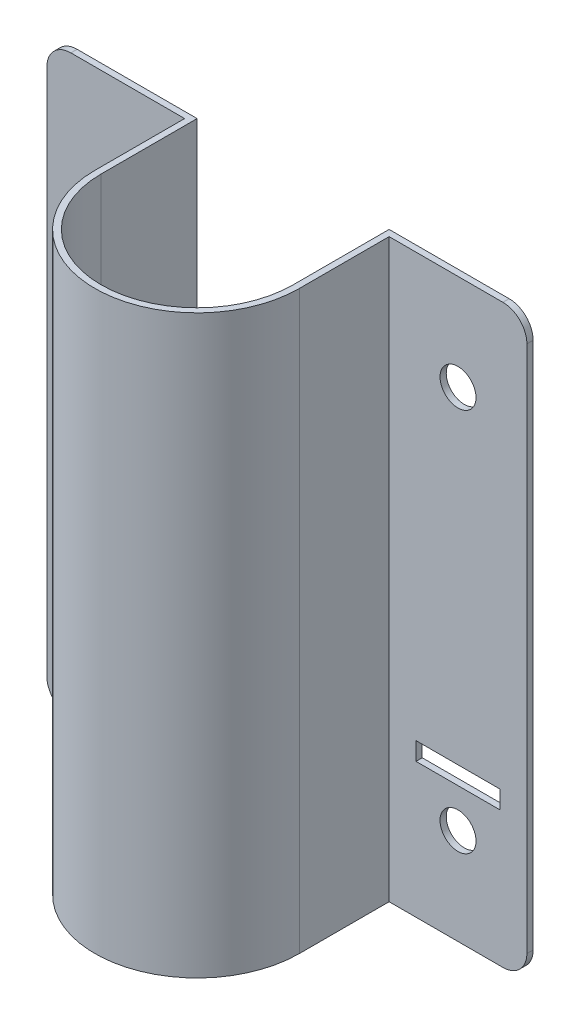
from build123d import *

# Parameters (mm, degrees)
BOSS_EXTRUDE1_DEPTH = 152.4
SKETCH2_R           = 4.7625
CUT_EXTRUDE1_DEPTH  = 50.8
FILLET1_R           = 6.35
SKETCH3_W           = 22.225
SKETCH3_H           = 4.7625
CUT_EXTRUDE3_DEPTH  = 2.651


with BuildPart() as part:
    # Sketch1 → Boss-Extrude1 (new body)
    with BuildSketch(Plane(origin=(0, 0, 0), x_dir=(1, 0, 0), z_dir=(0, 1, 0))):
        with BuildLine():
            Line((-27.051, 0), (-27.051, 23.749))
            Line((-27.051, 23.749), (-63.5, 23.749))
            Line((-63.5, 23.749), (-63.5, 25.4))
            Line((-63.5, 25.4), (-25.4, 25.4))
            Line((-25.4, 25.4), (-25.4, 0))
            ThreePointArc((-25.4, 0), (0, -25.4), (25.4, 0))
            Line((25.4, 0), (25.4, 25.4))
            Line((25.4, 25.4), (63.5, 25.4))
            Line((63.5, 25.4), (63.5, 23.749))
            Line((63.5, 23.749), (27.051, 23.749))
            Line((27.051, 23.749), (27.051, 0))
            ThreePointArc((27.051, 0), (0, -27.051), (-27.051, 0))
        make_face()
    extrude(amount=-BOSS_EXTRUDE1_DEPTH)

    # Sketch2 → Cut-Extrude1 (cut)
    with BuildSketch(Plane.XY.offset(-23.749)):
        with Locations((-45.2755, -25.4)):
            Circle(SKETCH2_R)
        with Locations((45.2755, -25.4)):
            Circle(SKETCH2_R)
        with Locations((-45.2755, -127)):
            Circle(SKETCH2_R)
        with Locations((45.2755, -127)):
            Circle(SKETCH2_R)
    extrude(amount=-CUT_EXTRUDE1_DEPTH, mode=Mode.SUBTRACT)

    # Fillet1
    fillet1_edges = [part.edges().sort_by_distance(p)[0] for p in [
        (63.5, 0, -24.5745),
        (-63.5, 0, -24.5745),
        (-63.5, -152.4, -24.5745),
        (63.5, -152.4, -24.5745),
    ]]
    fillet(fillet1_edges, radius=FILLET1_R)

    # Sketch3 → Cut-Extrude3 (cut, through all)
    with BuildSketch(Plane.XY.offset(-23.749)):
        with Locations((45.2755, -114.3)):
            Rectangle(SKETCH3_W, SKETCH3_H)
        with Locations((-45.2755, -114.3)):
            Rectangle(SKETCH3_W, SKETCH3_H)
    extrude(amount=-CUT_EXTRUDE3_DEPTH, mode=Mode.SUBTRACT)


solid = part.part
